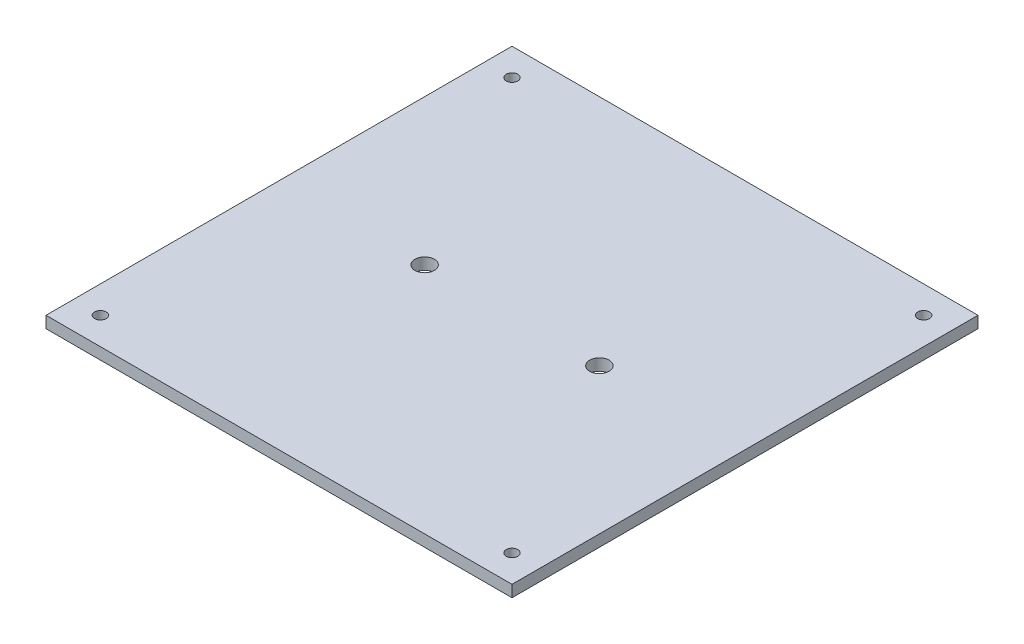
from build123d import *

# Parameters (mm, degrees)
SKETCH1_W           = 120
SKETCH1_H           = 120
BOSS_EXTRUDE1_DEPTH = 3
SKETCH4_R           = 2.5
CUT_EXTRUDE2_DEPTH  = 3
SKETCH7_R           = 1.5
CUT_EXTRUDE3_DEPTH  = 3


with BuildPart() as part:
    # Sketch1 → Boss-Extrude1 (new body)
    with BuildSketch(Plane(origin=(0, 0, 0), x_dir=(1, 0, 0), z_dir=(0, 1, 0))):
        Rectangle(SKETCH1_W, SKETCH1_H)
    extrude(amount=BOSS_EXTRUDE1_DEPTH)

    # Sketch4 → Cut-Extrude2 (cut)
    with BuildSketch(Plane(origin=(0, 0, 0), x_dir=(1, 0, 0), z_dir=(0, 1, 0))):
        with Locations((-22.5, 0)):
            Circle(SKETCH4_R)
        with Locations((22.5, 0)):
            Circle(SKETCH4_R)
    extrude(amount=CUT_EXTRUDE2_DEPTH, mode=Mode.SUBTRACT)

    # Sketch7 → Cut-Extrude3 (cut)
    with BuildSketch(Plane(origin=(0, 0, 0), x_dir=(1, 0, 0), z_dir=(0, 1, 0))):
        with Locations((-53, 53)):
            Circle(SKETCH7_R)
        with Locations((53, 53)):
            Circle(SKETCH7_R)
        with Locations((-53, -53)):
            Circle(SKETCH7_R)
        with Locations((53, -53)):
            Circle(SKETCH7_R)
    extrude(amount=CUT_EXTRUDE3_DEPTH, mode=Mode.SUBTRACT)


solid = part.part
